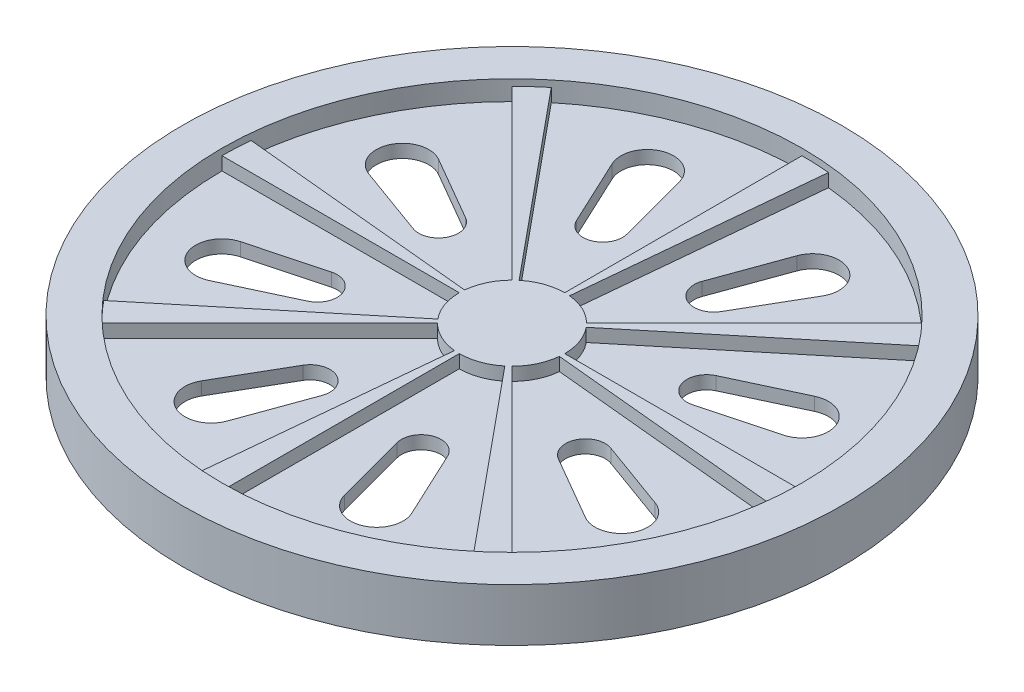
from build123d import *

# Parameters (mm, degrees)
BOSS_EXTRUDE2_DEPTH      = 2
BOSS_EXTRUDE2_DEPTH_BACK = 2
SKETCH1_R                = 25
SKETCH1_R_2              = 22
BOSS_EXTRUDE3_DEPTH      = 1.5
BOSS_EXTRUDE3_DEPTH_BACK = 1.5
BOSS_EXTRUDE5_DEPTH      = 0.5
BOSS_EXTRUDE5_DEPTH_BACK = 0.5


with BuildPart() as part:
    # Sketch1 → Boss-Extrude2 (new, two sides: drawn at the far end of the back side and taken through both)
    with BuildSketch(Plane(origin=(0, 0, 0), x_dir=(1, 0, 0), z_dir=(0, 1, 0)).offset(-BOSS_EXTRUDE2_DEPTH_BACK)):
        Circle(SKETCH1_R)
        Circle(SKETCH1_R_2, mode=Mode.SUBTRACT)
    extrude(amount=BOSS_EXTRUDE2_DEPTH + BOSS_EXTRUDE2_DEPTH_BACK)

    # Sketch1_5 → Boss-Extrude3 (add, two sides: drawn at the far end of the back side and taken through both)
    with BuildSketch(Plane(origin=(0, 0, 0), x_dir=(1, 0, 0), z_dir=(0, 1, 0)).offset(-BOSS_EXTRUDE3_DEPTH_BACK)):
        with BuildLine():
            Line((0, 22), (0, 4))
            ThreePointArc((0, 4), (-1.351805959, 3.764654121), (-2.544540937, 3.086310325))
            Line((-2.544540937, 3.086310325), (-13.994975151, 16.974706787))
            ThreePointArc((-13.994975151, 16.974706787), (-14.792671398, 16.284252298), (-15.556349186, 15.556349186))
            Line((-15.556349186, 15.556349186), (-2.828427125, 2.828427125))
            ThreePointArc((-2.828427125, 2.828427125), (-3.617883618, 1.706141297), (-3.981613111, 0.383088808))
            Line((-3.981613111, 0.383088808), (-21.89887211, 2.106988446))
            ThreePointArc((-21.89887211, 2.106988446), (-21.974703484, 1.054706969), (-22, 0))
            Line((-22, 0), (-4, 0))
            ThreePointArc((-4, 0), (-3.764654121, -1.351805959), (-3.086310325, -2.544540937))
            Line((-3.086310325, -2.544540937), (-16.974706787, -13.994975151))
            ThreePointArc((-16.974706787, -13.994975151), (-16.284252298, -14.792671398), (-15.556349186, -15.556349186))
            Line((-15.556349186, -15.556349186), (-2.828427125, -2.828427125))
            ThreePointArc((-2.828427125, -2.828427125), (-1.706141297, -3.617883618), (-0.383088808, -3.981613111))
            Line((-0.383088808, -3.981613111), (-2.106988446, -21.89887211))
            ThreePointArc((-2.106988446, -21.89887211), (-1.054706969, -21.974703484), (0, -22))
            Line((0, -22), (0, -4))
            ThreePointArc((0, -4), (1.351805959, -3.764654121), (2.544540937, -3.086310325))
            Line((2.544540937, -3.086310325), (13.994975151, -16.974706787))
            ThreePointArc((13.994975151, -16.974706787), (14.792671398, -16.284252298), (15.556349186, -15.556349186))
            Line((15.556349186, -15.556349186), (2.828427125, -2.828427125))
            ThreePointArc((2.828427125, -2.828427125), (3.617883618, -1.706141297), (3.981613111, -0.383088808))
            Line((3.981613111, -0.383088808), (21.89887211, -2.106988446))
            ThreePointArc((21.89887211, -2.106988446), (21.974703484, -1.054706969), (22, 0))
            Line((22, 0), (4, 0))
            ThreePointArc((4, 0), (3.764654121, 1.351805959), (3.086310325, 2.544540937))
            Line((3.086310325, 2.544540937), (16.974706787, 13.994975151))
            ThreePointArc((16.974706787, 13.994975151), (16.284252298, 14.792671398), (15.556349186, 15.556349186))
            Line((15.556349186, 15.556349186), (2.828427125, 2.828427125))
            ThreePointArc((2.828427125, 2.828427125), (1.706141297, 3.617883618), (0.383088808, 3.981613111))
            Line((0.383088808, 3.981613111), (2.106988446, 21.89887211))
            ThreePointArc((2.106988446, 21.89887211), (1.054706969, 21.974703484), (0, 22))
        make_face()
    extrude(amount=BOSS_EXTRUDE3_DEPTH + BOSS_EXTRUDE3_DEPTH_BACK)

    # Sketch1_7 → Boss-Extrude5 (add, two sides: drawn at the far end of the back side and taken through both)
    # profile 1 of 8: a face of its own
    with BuildSketch(Plane(origin=(0, 0, 0), x_dir=(1, 0, 0), z_dir=(0, 1, 0)).offset(-BOSS_EXTRUDE5_DEPTH_BACK)):
        with BuildLine():
            ThreePointArc((-2.544540937, 3.086310325), (-1.351805959, 3.764654121), (0, 4))
            Line((0, 4), (0, 22))
            ThreePointArc((0, 22), (-7.434932773, 20.705597665), (-13.994975151, 16.974706787))
            Line((-13.994975151, 16.974706787), (-2.544540937, 3.086310325))
        make_face()
        with BuildLine():
            ThreePointArc((-2.491260012, 11.213267971), (-3.427551917, 9.417121496), (-5.299333827, 10.191212687))
            Line((-5.299333827, 10.191212687), (-7.680574112, 15.28292057))
            ThreePointArc((-7.680574112, 15.28292057), (-6.554010177, 18.006994968), (-3.940010864, 16.644374252))
            Line((-3.940010864, 16.644374252), (-2.491260012, 11.213267971))
        make_face(mode=Mode.SUBTRACT)
    # profile 2 of 8: a face of its own
    with BuildSketch(Plane(origin=(0, 0, 0), x_dir=(1, 0, 0), z_dir=(0, 1, 0)).offset(-BOSS_EXTRUDE5_DEPTH_BACK)):
        with BuildLine():
            Line((2.106988446, 21.89887211), (0.383088808, 3.981613111))
            ThreePointArc((0.383088808, 3.981613111), (1.706141297, 3.617883618), (2.828427125, 2.828427125))
            Line((2.828427125, 2.828427125), (15.556349186, 15.556349186))
            ThreePointArc((15.556349186, 15.556349186), (9.383777136, 19.898359899), (2.106988446, 21.89887211))
        make_face()
        with BuildLine():
            ThreePointArc((6.167390973, 9.69056467), (4.235265266, 9.082555673), (3.459080714, 10.953470484))
            Line((3.459080714, 10.953470484), (5.375670734, 16.237642809))
            ThreePointArc((5.375670734, 16.237642809), (8.098483211, 17.367253291), (8.983341502, 14.555358302))
            Line((8.983341502, 14.555358302), (6.167390973, 9.69056467))
        make_face(mode=Mode.SUBTRACT)
    # profile 3 of 8: a face of its own
    with BuildSketch(Plane(origin=(0, 0, 0), x_dir=(1, 0, 0), z_dir=(0, 1, 0)).offset(-BOSS_EXTRUDE5_DEPTH_BACK)):
        with BuildLine():
            ThreePointArc((-3.981613111, 0.383088808), (-3.617883618, 1.706141297), (-2.828427125, 2.828427125))
            Line((-2.828427125, 2.828427125), (-15.556349186, 15.556349186))
            ThreePointArc((-15.556349186, 15.556349186), (-19.898359899, 9.383777136), (-21.89887211, 2.106988446))
            Line((-21.89887211, 2.106988446), (-3.981613111, 0.383088808))
        make_face()
        with BuildLine():
            ThreePointArc((-9.69056467, 6.167390973), (-9.082555673, 4.235265266), (-10.953470484, 3.459080714))
            Line((-10.953470484, 3.459080714), (-16.237642809, 5.375670734))
            ThreePointArc((-16.237642809, 5.375670734), (-17.367253291, 8.098483211), (-14.555358302, 8.983341502))
            Line((-14.555358302, 8.983341502), (-9.69056467, 6.167390973))
        make_face(mode=Mode.SUBTRACT)
    # profile 4 of 8: a face of its own
    with BuildSketch(Plane(origin=(0, 0, 0), x_dir=(1, 0, 0), z_dir=(0, 1, 0)).offset(-BOSS_EXTRUDE5_DEPTH_BACK)):
        with BuildLine():
            Line((16.974706787, 13.994975151), (3.086310325, 2.544540937))
            ThreePointArc((3.086310325, 2.544540937), (3.764654121, 1.351805959), (4, 0))
            Line((4, 0), (22, 0))
            ThreePointArc((22, 0), (20.705597665, 7.434932773), (16.974706787, 13.994975151))
        make_face()
        with BuildLine():
            ThreePointArc((11.213267971, 2.491260012), (9.417121496, 3.427551917), (10.191212687, 5.299333827))
            Line((10.191212687, 5.299333827), (15.28292057, 7.680574112))
            ThreePointArc((15.28292057, 7.680574112), (18.006994968, 6.554010177), (16.644374252, 3.940010864))
            Line((16.644374252, 3.940010864), (11.213267971, 2.491260012))
        make_face(mode=Mode.SUBTRACT)
    # profile 5 of 8: a face of its own
    with BuildSketch(Plane(origin=(0, 0, 0), x_dir=(1, 0, 0), z_dir=(0, 1, 0)).offset(-BOSS_EXTRUDE5_DEPTH_BACK)):
        with BuildLine():
            ThreePointArc((-3.086310325, -2.544540937), (-3.764654121, -1.351805959), (-4, 0))
            Line((-4, 0), (-22, 0))
            ThreePointArc((-22, 0), (-20.705597665, -7.434932773), (-16.974706787, -13.994975151))
            Line((-16.974706787, -13.994975151), (-3.086310325, -2.544540937))
        make_face()
        with BuildLine():
            ThreePointArc((-11.213267971, -2.491260012), (-9.417121496, -3.427551917), (-10.191212687, -5.299333827))
            Line((-10.191212687, -5.299333827), (-15.28292057, -7.680574112))
            ThreePointArc((-15.28292057, -7.680574112), (-18.006994968, -6.554010177), (-16.644374252, -3.940010864))
            Line((-16.644374252, -3.940010864), (-11.213267971, -2.491260012))
        make_face(mode=Mode.SUBTRACT)
    # profile 6 of 8: a face of its own
    with BuildSketch(Plane(origin=(0, 0, 0), x_dir=(1, 0, 0), z_dir=(0, 1, 0)).offset(-BOSS_EXTRUDE5_DEPTH_BACK)):
        with BuildLine():
            Line((21.89887211, -2.106988446), (3.981613111, -0.383088808))
            ThreePointArc((3.981613111, -0.383088808), (3.617883618, -1.706141297), (2.828427125, -2.828427125))
            Line((2.828427125, -2.828427125), (15.556349186, -15.556349186))
            ThreePointArc((15.556349186, -15.556349186), (19.898359899, -9.383777136), (21.89887211, -2.106988446))
        make_face()
        with BuildLine():
            ThreePointArc((9.69056467, -6.167390973), (9.082555673, -4.235265266), (10.953470484, -3.459080714))
            Line((10.953470484, -3.459080714), (16.237642809, -5.375670734))
            ThreePointArc((16.237642809, -5.375670734), (17.367253291, -8.098483211), (14.555358302, -8.983341502))
            Line((14.555358302, -8.983341502), (9.69056467, -6.167390973))
        make_face(mode=Mode.SUBTRACT)
    # profile 7 of 8: a face of its own
    with BuildSketch(Plane(origin=(0, 0, 0), x_dir=(1, 0, 0), z_dir=(0, 1, 0)).offset(-BOSS_EXTRUDE5_DEPTH_BACK)):
        with BuildLine():
            ThreePointArc((-0.383088808, -3.981613111), (-1.706141297, -3.617883618), (-2.828427125, -2.828427125))
            Line((-2.828427125, -2.828427125), (-15.556349186, -15.556349186))
            ThreePointArc((-15.556349186, -15.556349186), (-9.383777136, -19.898359899), (-2.106988446, -21.89887211))
            Line((-2.106988446, -21.89887211), (-0.383088808, -3.981613111))
        make_face()
        with BuildLine():
            ThreePointArc((-6.167390973, -9.69056467), (-4.235265266, -9.082555673), (-3.459080714, -10.953470484))
            Line((-3.459080714, -10.953470484), (-5.375670734, -16.237642809))
            ThreePointArc((-5.375670734, -16.237642809), (-8.098483211, -17.367253291), (-8.983341502, -14.555358302))
            Line((-8.983341502, -14.555358302), (-6.167390973, -9.69056467))
        make_face(mode=Mode.SUBTRACT)
    # profile 8 of 8: a face of its own
    with BuildSketch(Plane(origin=(0, 0, 0), x_dir=(1, 0, 0), z_dir=(0, 1, 0)).offset(-BOSS_EXTRUDE5_DEPTH_BACK)):
        with BuildLine():
            Line((13.994975151, -16.974706787), (2.544540937, -3.086310325))
            ThreePointArc((2.544540937, -3.086310325), (1.351805959, -3.764654121), (0, -4))
            Line((0, -4), (0, -22))
            ThreePointArc((0, -22), (7.434932773, -20.705597665), (13.994975151, -16.974706787))
        make_face()
        with BuildLine():
            ThreePointArc((2.491260012, -11.213267971), (3.427551917, -9.417121496), (5.299333827, -10.191212687))
            Line((5.299333827, -10.191212687), (7.680574112, -15.28292057))
            ThreePointArc((7.680574112, -15.28292057), (6.554010177, -18.006994968), (3.940010864, -16.644374252))
            Line((3.940010864, -16.644374252), (2.491260012, -11.213267971))
        make_face(mode=Mode.SUBTRACT)
    extrude(amount=BOSS_EXTRUDE5_DEPTH + BOSS_EXTRUDE5_DEPTH_BACK)


solid = part.part
